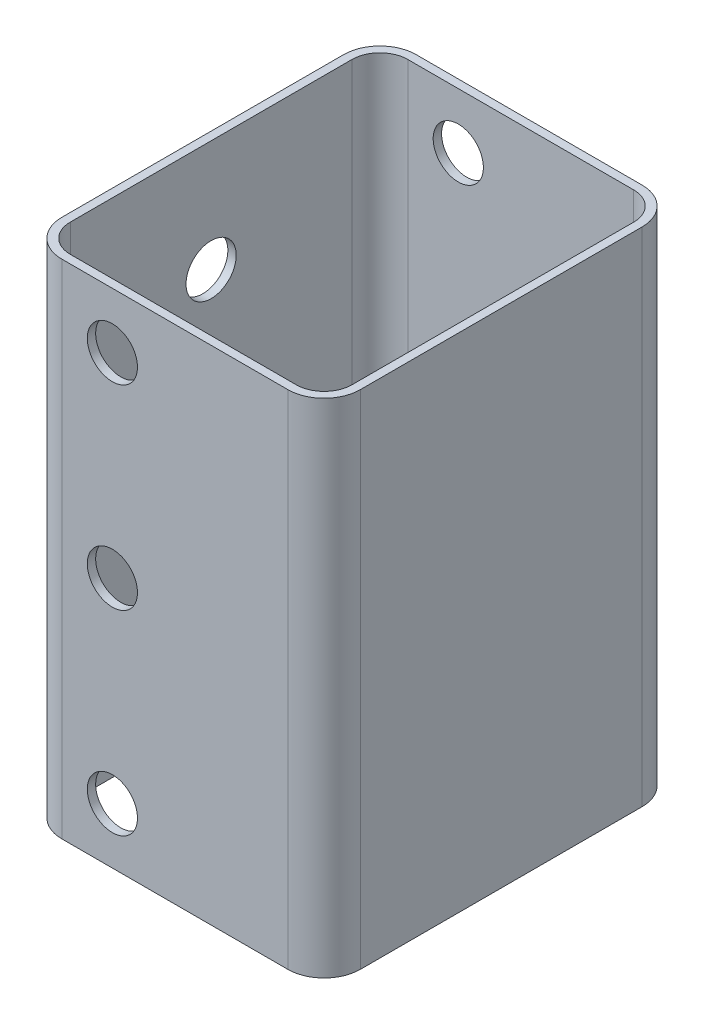
from build123d import *

# Parameters (mm, degrees)
BOSS_EXTRUDE1_DEPTH = 90
SKETCH2_R           = 4.5
CUT_EXTRUDE1_DEPTH  = 10
SKETCH3_R           = 4.5
CUT_EXTRUDE2_DEPTH  = 95


with BuildPart() as part:
    # Sketch1 → Boss-Extrude1 (new body)
    with BuildSketch(Plane(origin=(0, 0, 0), x_dir=(1, 0, 0), z_dir=(0, 1, 0))):
        with BuildLine():
            Line((-20.25, -31.75), (20.25, -31.75))
            ThreePointArc((20.25, -31.75), (24.846194078, -29.846194078), (26.75, -25.25))
            Line((26.75, -25.25), (26.75, 25.25))
            ThreePointArc((26.75, 25.25), (24.846194078, 29.846194078), (20.25, 31.75))
            Line((20.25, 31.75), (-20.25, 31.75))
            ThreePointArc((-20.25, 31.75), (-24.846194078, 29.846194078), (-26.75, 25.25))
            Line((-26.75, 25.25), (-26.75, -25.25))
            ThreePointArc((-26.75, -25.25), (-24.846194078, -29.846194078), (-20.25, -31.75))
        make_face()
        with BuildLine():
            Line((-20.25, -30.25), (20.25, -30.25))
            ThreePointArc((20.25, -30.25), (23.785533906, -28.785533906), (25.25, -25.25))
            Line((25.25, -25.25), (25.25, 25.25))
            ThreePointArc((25.25, 25.25), (23.785533906, 28.785533906), (20.25, 30.25))
            Line((20.25, 30.25), (-20.25, 30.25))
            ThreePointArc((-20.25, 30.25), (-23.785533906, 28.785533906), (-25.25, 25.25))
            Line((-25.25, 25.25), (-25.25, -25.25))
            ThreePointArc((-25.25, -25.25), (-23.785533906, -28.785533906), (-20.25, -30.25))
        make_face(mode=Mode.SUBTRACT)
    extrude(amount=BOSS_EXTRUDE1_DEPTH)

    # Sketch2 → Cut-Extrude1 (cut)
    with BuildSketch(Plane.ZY.offset(34.75)):
        with Locations((0, 70)):
            Circle(SKETCH2_R)
        with Locations((0, 20)):
            Circle(SKETCH2_R)
    extrude(amount=-CUT_EXTRUDE1_DEPTH, mode=Mode.SUBTRACT)

    # Sketch3 → Cut-Extrude2 (cut)
    with BuildSketch(Plane.XY.offset(32.25)):
        with Locations((-11.2, 80)):
            Circle(SKETCH3_R)
        with Locations((-11.2, 10)):
            Circle(SKETCH3_R)
        with Locations((-11.2, 45)):
            Circle(SKETCH3_R)
    extrude(amount=-CUT_EXTRUDE2_DEPTH, mode=Mode.SUBTRACT)


solid = part.part
